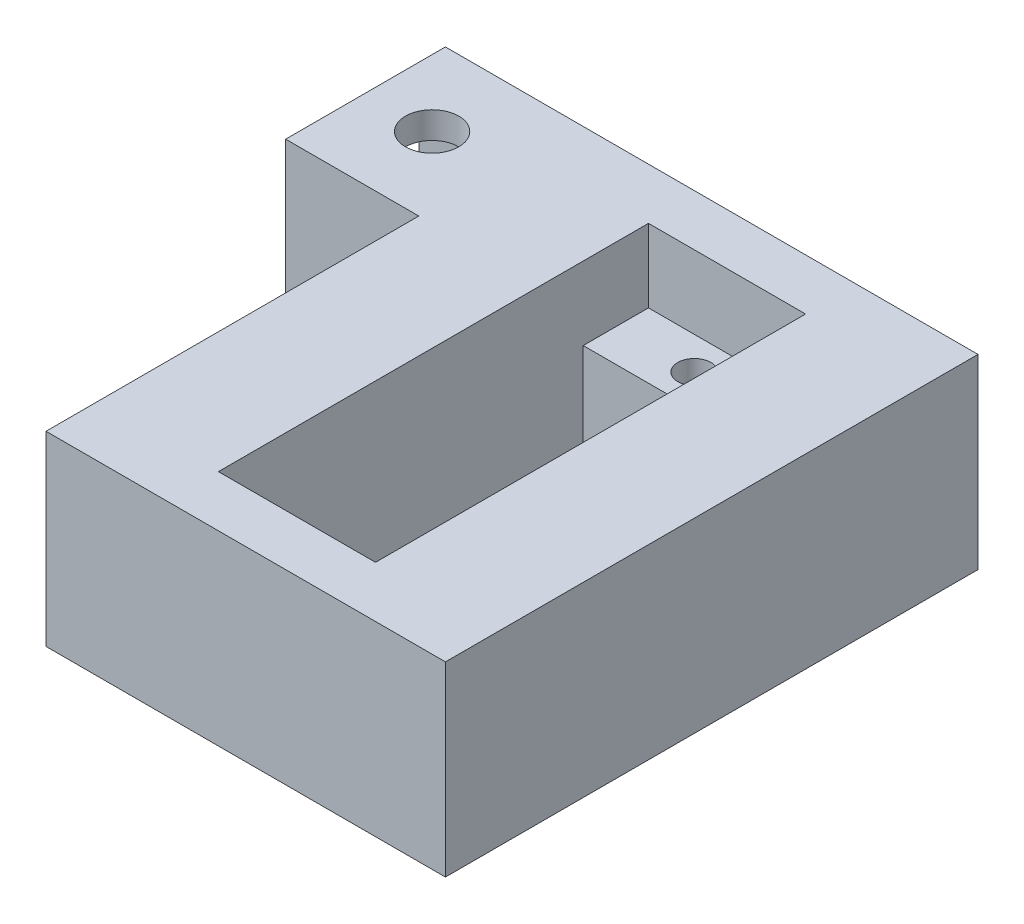
from build123d import *

# Parameters (mm, degrees)
BOSS_EXTRUDE1_DEPTH = 40
SKETCH4_W           = 11.8
SKETCH4_H           = 32.3
CUT_EXTRUDE1_DEPTH  = 5.5
SKETCH5_W           = 11.8
SKETCH5_H           = 22.5
CUT_EXTRUDE2_DEPTH  = 9.498848241
SKETCH6_R           = 1.25
CUT_EXTRUDE3_DEPTH  = 9.498848241
SKETCH7_W           = 12
SKETCH7_H           = 13.998848241
BOSS_EXTRUDE2_DEPTH = 10
SKETCH8_W           = 8
SKETCH8_H           = 9.998848241
CUT_EXTRUDE6_DEPTH  = 10
SKETCH9_R           = 2
CUT_EXTRUDE7_DEPTH  = 14.998848241


with BuildPart() as part:
    # Sketch1 → Boss-Extrude1 (new body)
    with BuildSketch(Plane.XY):
        Polygon((8.670952565, 9.003587153), (-11.329047435, 9.003587153), (-21.329047435, 9.003587153), (-21.329047435, -4.995261088), (-11.329047435, -4.995261088), (8.670952565, -4.995261088), align=None)
    extrude(amount=BOSS_EXTRUDE1_DEPTH)

    # Sketch4 → Cut-Extrude1 (cut)
    with BuildSketch(Plane(origin=(0, 9.003587153, 0), x_dir=(1, 0, 0), z_dir=(0, 1, 0))):
        with Locations((-6.329047435, -20)):
            Rectangle(SKETCH4_W, SKETCH4_H)
    extrude(amount=-CUT_EXTRUDE1_DEPTH, mode=Mode.SUBTRACT)

    # Sketch5 → Cut-Extrude2 (cut, through all)
    with BuildSketch(Plane(origin=(0, 3.503587153, 0), x_dir=(1, 0, 0), z_dir=(0, 1, 0))):
        with Locations((-6.329047435, -20)):
            Rectangle(SKETCH5_W, SKETCH5_H)
    extrude(amount=-CUT_EXTRUDE2_DEPTH, mode=Mode.SUBTRACT)

    # Sketch6 → Cut-Extrude3 (cut, through all)
    with BuildSketch(Plane(origin=(0, 3.503587153, 0), x_dir=(1, 0, 0), z_dir=(0, 1, 0))):
        with Locations((-6.329047435, -6.3)):
            Circle(SKETCH6_R)
        with Locations((-6.329047435, -33.7)):
            Circle(SKETCH6_R)
    extrude(amount=-CUT_EXTRUDE3_DEPTH, mode=Mode.SUBTRACT)

    # Sketch7 → Boss-Extrude2 (add)
    with BuildSketch(Plane.ZY.offset(21.329047435)):
        with Locations((6, 2.004163032)):
            Rectangle(SKETCH7_W, SKETCH7_H)
    extrude(amount=BOSS_EXTRUDE2_DEPTH)

    # Sketch8 → Cut-Extrude6 (cut)
    with BuildSketch(Plane.ZY.offset(31.329047435)):
        with Locations((6, 2.004163033)):
            Rectangle(SKETCH8_W, SKETCH8_H)
    extrude(amount=-CUT_EXTRUDE6_DEPTH, mode=Mode.SUBTRACT)

    # Sketch9 → Cut-Extrude7 (cut, through all)
    with BuildSketch(Plane(origin=(0, 9.003587153, 0), x_dir=(1, 0, 0), z_dir=(0, 1, 0))):
        with Locations((-26.329047435, -6)):
            Circle(SKETCH9_R)
    extrude(amount=-CUT_EXTRUDE7_DEPTH, mode=Mode.SUBTRACT)


solid = part.part
